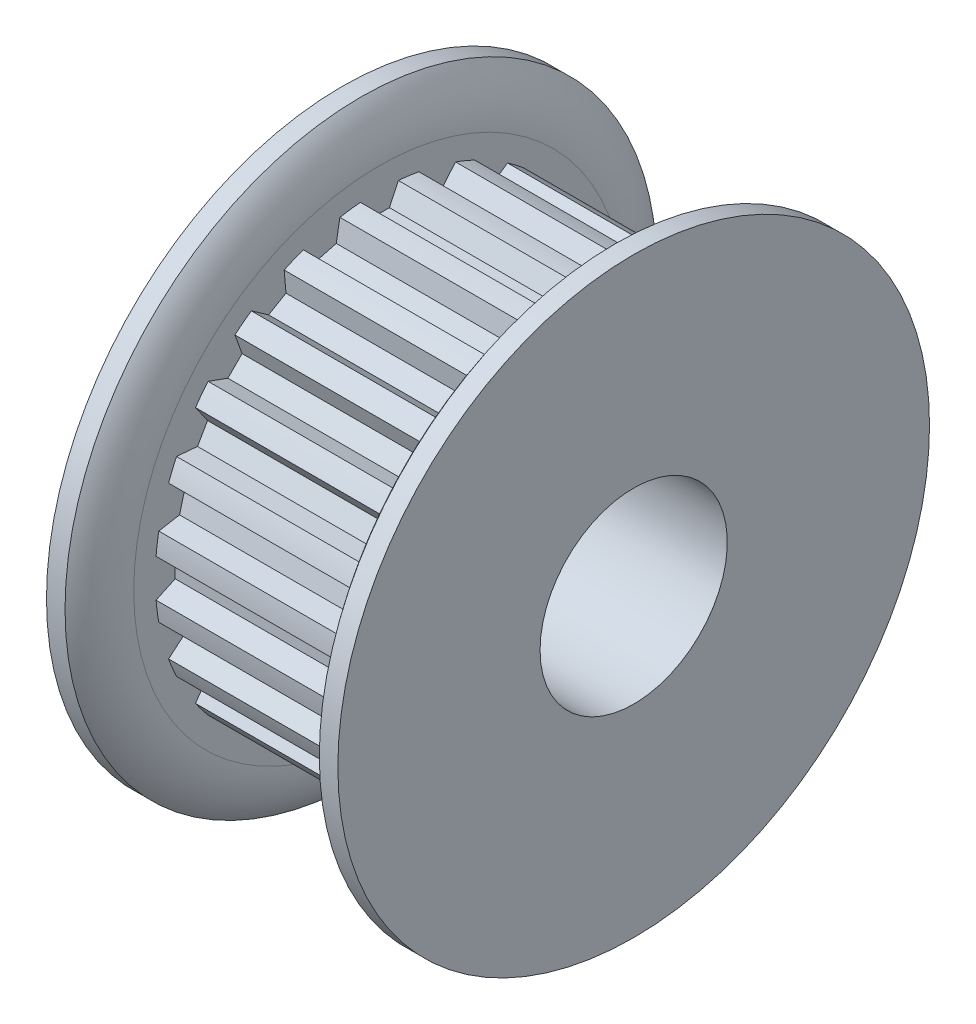
from build123d import *

# Parameters (mm, degrees)
SKETCH4_R          = 7.7597
SKETCH4_R_2        = 7.60095
CUT_EXTRUDE2_DEPTH = 7.366
CUT_EXTRUDE1_DEPTH = 7.366
CIRPATTERN1_COUNT  = 24
SKETCH6_R          = 1.4605
CUT_EXTRUDE3_DEPTH = 17.66336796
CUT_EXTRUDE4_DEPTH = 1.016
CIRPATTERN2_COUNT  = 2
CIRPATTERN2_ANGLE  = 90
CIRPATTERN3_COUNT  = 2
CIRPATTERN3_ANGLE  = 90
SKETCH9_W          = 8.047950053
SKETCH9_H          = 15.828316952
CUT_EXTRUDE5_DEPTH = 7.62


with BuildPart() as part:
    # Sketch1 → Revolve1 (revolve)
    with BuildSketch(Plane.XY, mode=Mode.PRIVATE) as revolve1_sk:
        with BuildLine():
            Line((-8.7376, 3.175), (8.7376, 3.175))
            Line((8.7376, 3.175), (8.7376, 10.033))
            Line((8.7376, 10.033), (8.10895, 10.033))
            ThreePointArc((8.10895, 10.033), (7.642486723, 9.238300334), (7.4803, 8.3312))
            Line((7.4803, 8.3312), (7.4803, 7.7597))
            Line((7.4803, 7.7597), (0.1143, 7.7597))
            Line((0.1143, 7.7597), (0.1143, 8.3312))
            ThreePointArc((0.1143, 8.3312), (-0.047886723, 9.238300334), (-0.51435, 10.033))
            Line((-0.51435, 10.033), (-1.143, 10.033))
            Line((-1.143, 10.033), (-1.143, 5.6134))
            Line((-1.143, 5.6134), (-8.7376, 5.6134))
            Line((-8.7376, 5.6134), (-8.7376, 3.175))
        make_face()
    revolve(revolve1_sk.sketch.rotate(Axis((-8.7376, 0, 0), (1, 0, 0)), 90), axis=Axis((-8.7376, 0, 0), (1, 0, 0)))

    # Sketch4 → Cut-Extrude2 (cut)
    with BuildSketch(Plane(origin=(0.1143, 0, 0), x_dir=(0, 0, -1), z_dir=(1, 0, 0))):
        Circle(SKETCH4_R)
        Circle(SKETCH4_R_2, mode=Mode.SUBTRACT)
    extrude(amount=CUT_EXTRUDE2_DEPTH, mode=Mode.SUBTRACT)

    # Sketch3 → Cut-Extrude1 (cut)
    with BuildSketch(Plane(origin=(0.1143, 0, 0), x_dir=(0, 0, -1), z_dir=(1, 0, 0))):
        with BuildLine():
            Line((-0.643066132, 7.57369836), (-0.340952079, 6.925812683))
            Line((-0.340952079, 6.925812683), (0.340952079, 6.925812683))
            Line((0.340952079, 6.925812683), (0.643066132, 7.57369836))
            ThreePointArc((0.643066132, 7.57369836), (0, 7.60095), (-0.643066132, 7.57369836))
        make_face()
    cut_extrude1 = extrude(amount=CUT_EXTRUDE1_DEPTH, mode=Mode.SUBTRACT)

    # CirPattern1: Cut-Extrude1 ×24 about axis
    cirpattern1_axis = Axis((0, 0, 0), (1, 0, 0))
    for i in range(1, CIRPATTERN1_COUNT):
        add(cut_extrude1.rotate(cirpattern1_axis, i * 360 / CIRPATTERN1_COUNT), mode=Mode.SUBTRACT)

    # Sketch6 → Cut-Extrude3 (cut, through all)
    with BuildSketch(Plane(origin=(0, 0, 0), x_dir=(1, 0, 0), z_dir=(0, 1, 0))):
        with Locations(Location((-4.9403, 0, 0), (0, 0, 90))):
            Circle(SKETCH6_R)
    cut_extrude3 = extrude(amount=CUT_EXTRUDE3_DEPTH, mode=Mode.SUBTRACT)

    # CirPattern2: Cut-Extrude3 ×2 about axis
    cirpattern2_axis = Axis((-8.7376, 0, 0), (1, 0, 0))
    for i in range(1, CIRPATTERN2_COUNT):
        add(cut_extrude3.rotate(cirpattern2_axis, i * CIRPATTERN2_ANGLE / (CIRPATTERN2_COUNT - 1)), mode=Mode.SUBTRACT)


with BuildPart() as body_2:
    # Sketch7 → Revolve2 (revolve)
    with BuildSketch(Plane.XY, mode=Mode.PRIVATE) as revolve2_sk:
        Polygon((-6.1087, 5.6134), (-4.9403, 5.6134), (-4.9403, 3.556), (-6.1087, 3.556), (-6.3627, 3.81), (-6.3627, 5.3594), align=None)
    revolve(revolve2_sk.sketch.rotate(Axis((-4.9403, 3.556, 0), (0, 1, 0)), 270), axis=Axis((-4.9403, 3.556, 0), (0, 1, 0)))

    # Sketch8 → Cut-Extrude4 (cut)
    with BuildSketch(Plane(origin=(0, 5.6134, 0), x_dir=(1, 0, 0), z_dir=(0, 1, 0))):
        Polygon((-4.9403, 0.821223023), (-5.6515, 0.410611511), (-5.6515, -0.410611511), (-4.9403, -0.821223023), (-4.2291, -0.410611511), (-4.2291, 0.410611511), align=None)
    extrude(amount=-CUT_EXTRUDE4_DEPTH, mode=Mode.SUBTRACT)


with BuildPart() as cirpattern3_1:
    # CirPattern3: pattern copy
    add(body_2.part.rotate(Axis((0, 0, 0), (1, 0, 0)), 1 * CIRPATTERN3_ANGLE / (CIRPATTERN3_COUNT - 1)))


with BuildPart() as cut_extrude5_tool:
    # Sketch9 → Cut-Extrude5 (new, symmetric)
    with BuildSketch(Plane(origin=(0, 0, 0), x_dir=(1, 0, 0), z_dir=(0, 1, 0))):
        with Locations((-5.166975027, 0.16569051)):
            Rectangle(SKETCH9_W, SKETCH9_H)
    extrude(amount=CUT_EXTRUDE5_DEPTH, both=True)


with BuildPart() as part_1:
    add(part.part)

    # Cut-Extrude5: cut by cut_extrude5_tool
    add(cut_extrude5_tool.part, mode=Mode.SUBTRACT)


with BuildPart() as body_2_1:
    add(body_2.part)

    # Cut-Extrude5: cut by cut_extrude5_tool
    add(cut_extrude5_tool.part, mode=Mode.SUBTRACT)


with BuildPart() as cirpattern3_1_1:
    add(cirpattern3_1.part)

    # Cut-Extrude5: cut by cut_extrude5_tool
    add(cut_extrude5_tool.part, mode=Mode.SUBTRACT)


solid = part_1.part
